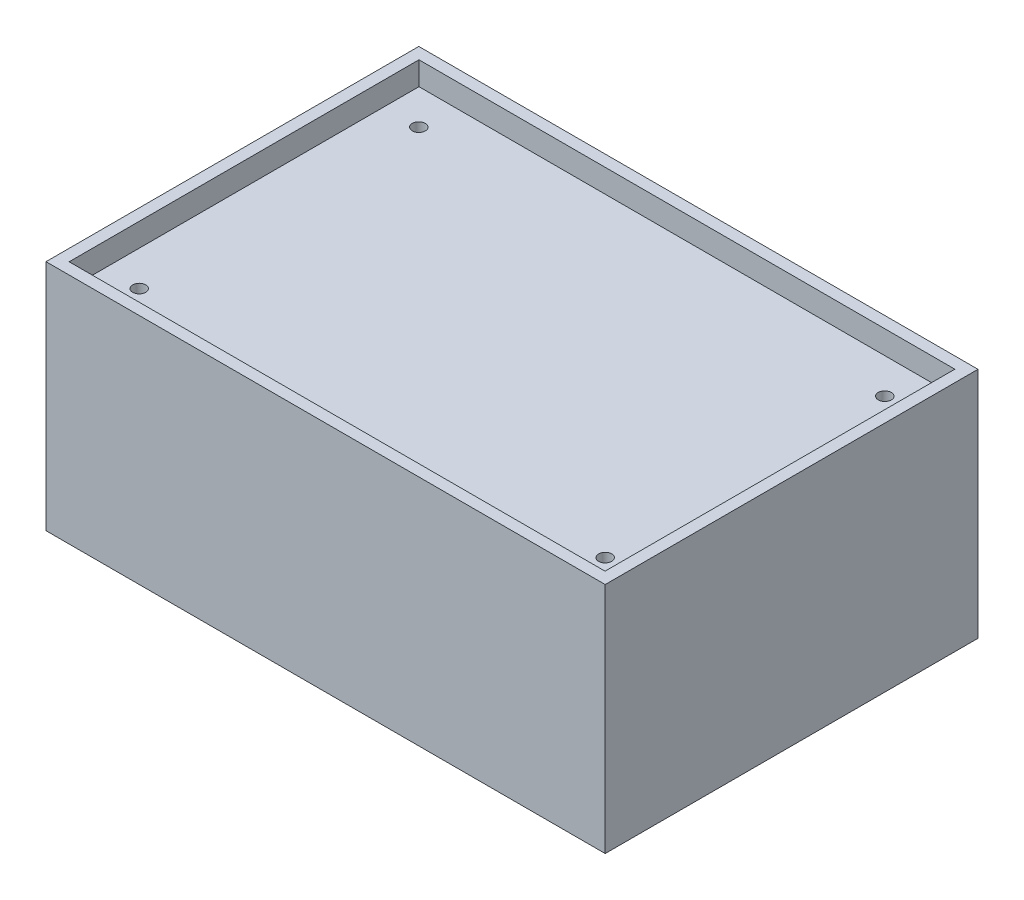
from build123d import *

# Parameters (mm, degrees)
SKETCH1_W           = 152.4
SKETCH1_H           = 63.5
BOSS_EXTRUDE1_DEPTH = 101.6
SKETCH3_W           = 146.05
SKETCH3_H           = 95.34
CUT_EXTRUDE1_DEPTH  = 6.35
SKETCH4_R           = 1.78
CUT_EXTRUDE2_DEPTH  = 10


with BuildPart() as part:
    # Sketch1 → Boss-Extrude1 (new body)
    with BuildSketch(Plane.XY):
        Rectangle(SKETCH1_W, SKETCH1_H)
    extrude(amount=-BOSS_EXTRUDE1_DEPTH)

    # Sketch3 → Cut-Extrude1 (cut)
    with BuildSketch(Plane(origin=(0, 31.75, 0), x_dir=(1, 0, 0), z_dir=(0, 1, 0))):
        with Locations((0, 50.8)):
            Rectangle(SKETCH3_W, SKETCH3_H)
    cut_extrude1 = extrude(amount=-CUT_EXTRUDE1_DEPTH, mode=Mode.SUBTRACT)

    # Mirror1: Cut-Extrude1 across plane
    add(cut_extrude1.mirror(Plane.ZX), mode=Mode.SUBTRACT)

    # Sketch4 → Cut-Extrude2 (cut)
    with BuildSketch(Plane(origin=(0, 25.4, 0), x_dir=(1, 0, 0), z_dir=(0, 1, 0))):
        with Locations((63.5, 88.9)):
            Circle(SKETCH4_R)
        with Locations((63.5, 12.7)):
            Circle(SKETCH4_R)
        with Locations((-63.5, 88.9)):
            Circle(SKETCH4_R)
        with Locations((-63.5, 12.7)):
            Circle(SKETCH4_R)
    extrude(amount=-CUT_EXTRUDE2_DEPTH, mode=Mode.SUBTRACT)


solid = part.part
